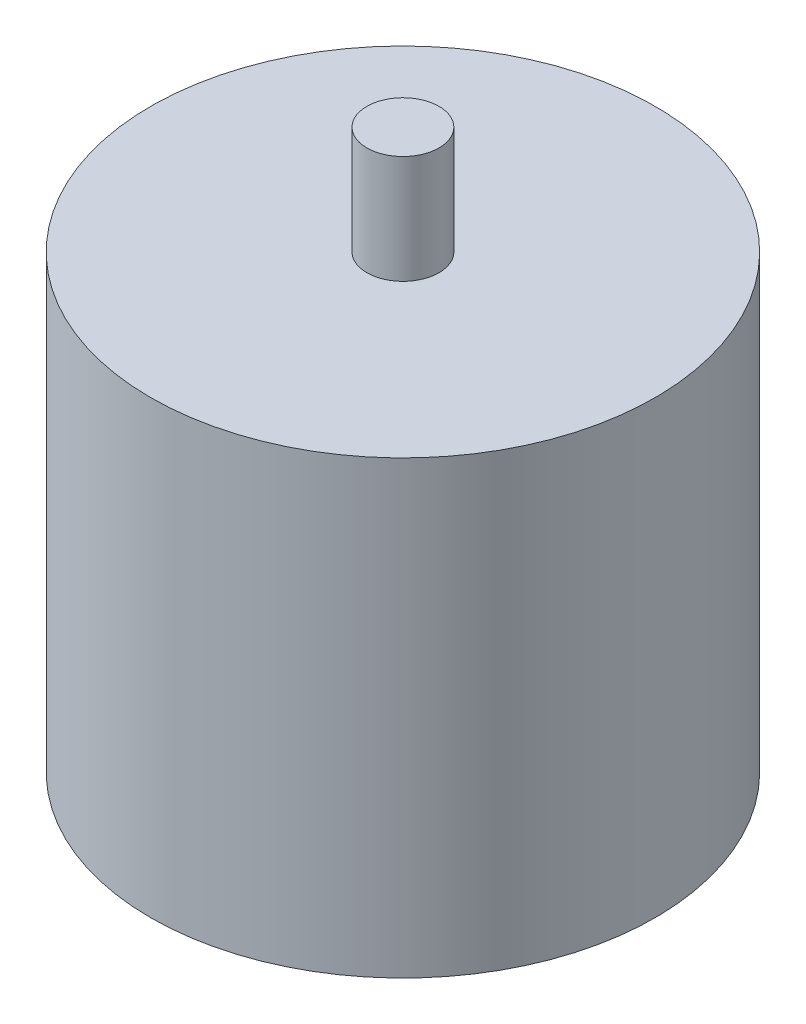
from build123d import *

# Parameters (mm, degrees)
SKETCH1_R           = 14
BOSS_EXTRUDE1_DEPTH = 25
SKETCH2_R           = 2
BOSS_EXTRUDE2_DEPTH = 6


with BuildPart() as part:
    # Sketch1 → Boss-Extrude1 (new body)
    with BuildSketch(Plane(origin=(0, 0, 0), x_dir=(1, 0, 0), z_dir=(0, 1, 0))):
        Circle(SKETCH1_R)
    extrude(amount=BOSS_EXTRUDE1_DEPTH)

    # Sketch2 → Boss-Extrude2 (add)
    with BuildSketch(Plane(origin=(0, 25, 0), x_dir=(1, 0, 0), z_dir=(0, 1, 0))):
        Circle(SKETCH2_R)
    extrude(amount=BOSS_EXTRUDE2_DEPTH)


solid = part.part
